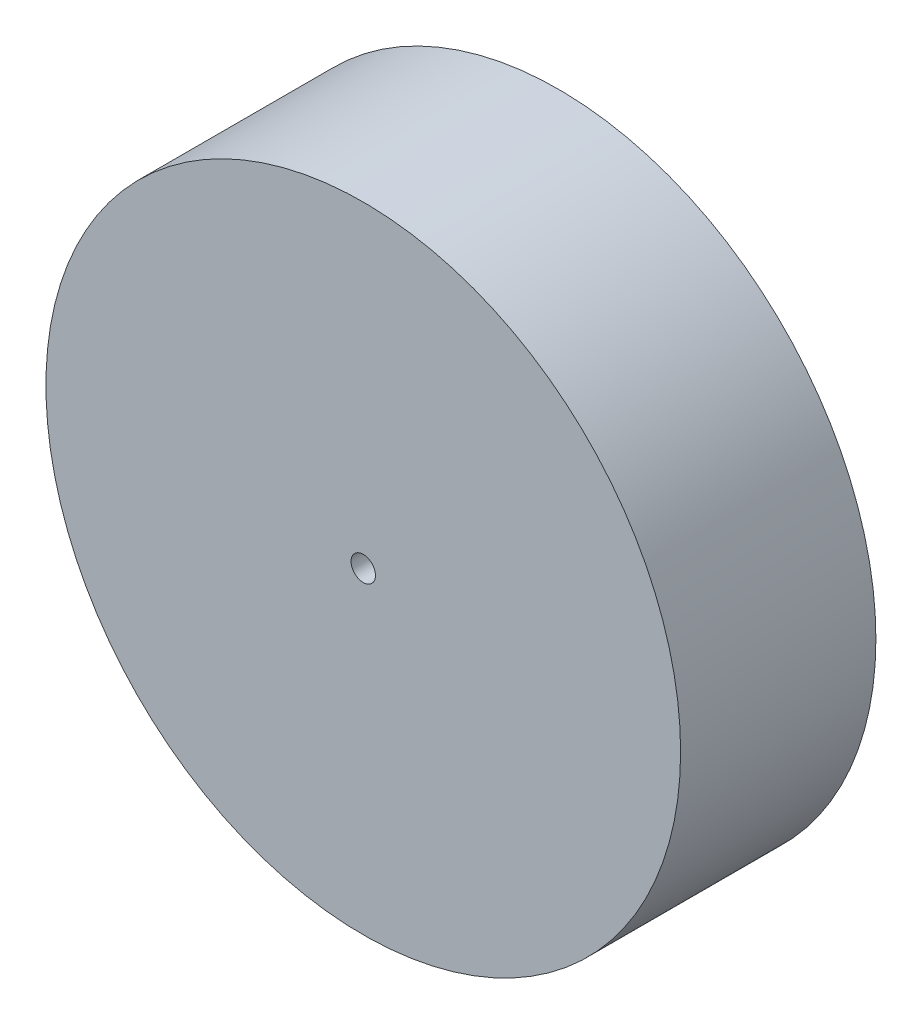
from build123d import *

# Parameters (mm, degrees)
SKETCH1_R           = 65
BOSS_EXTRUDE1_DEPTH = 40
SKETCH2_R           = 2.5
CUT_EXTRUDE1_DEPTH  = 41


with BuildPart() as part:
    # Sketch1 → Boss-Extrude1 (new body)
    with BuildSketch(Plane.XY):
        Circle(SKETCH1_R)
    extrude(amount=BOSS_EXTRUDE1_DEPTH)

    # Sketch2 → Cut-Extrude1 (cut, through all)
    with BuildSketch(Plane.XY):
        Circle(SKETCH2_R)
    extrude(amount=CUT_EXTRUDE1_DEPTH, mode=Mode.SUBTRACT)


solid = part.part
